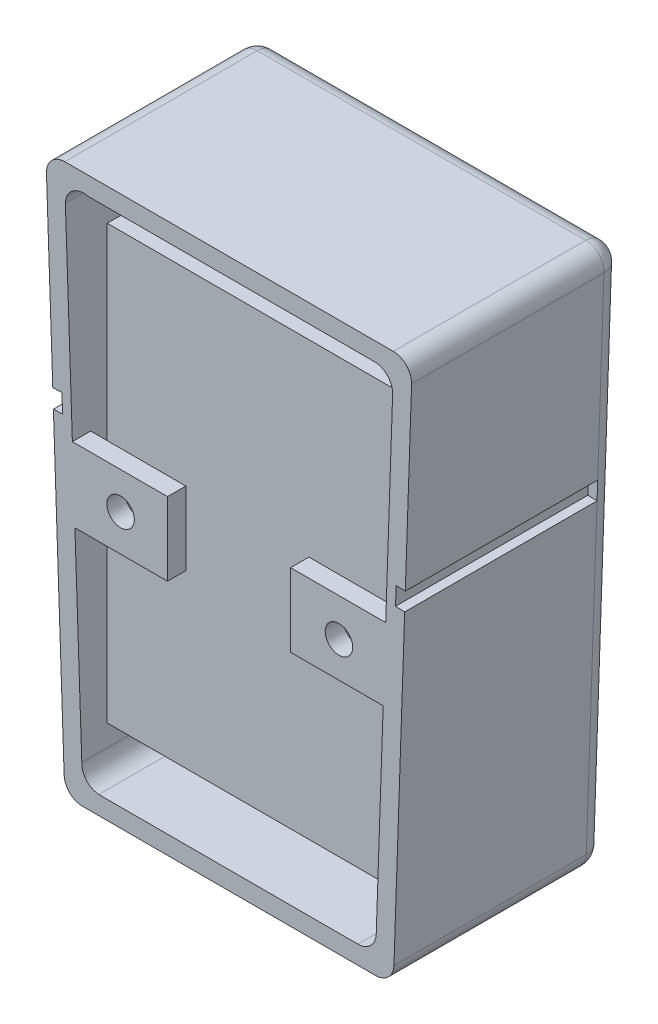
from build123d import *

# Parameters (mm, degrees)
SKETCH1_R           = 3.75
SKETCH1_R_2         = 12.75
BOSS_EXTRUDE1_DEPTH = 3.81
BOSS_EXTRUDE3_DEPTH = 25.4
BOSS_EXTRUDE4_DEPTH = 2.54
FILLET1_R           = 2.54
BOSS_EXTRUDE6_DEPTH = 2.54
SKETCH9_R           = 1.905
CUT_EXTRUDE1_DEPTH  = 2.54
CUT_EXTRUDE2_DEPTH  = 1.27
SKETCH11_W          = 26.67
SKETCH11_H          = 2.54
CUT_EXTRUDE3_DEPTH  = 1.27
SKETCH12_W          = 26.67
SKETCH12_H          = 2.54
CUT_EXTRUDE4_DEPTH  = 1.27
SKETCH13_W          = 39.9796
SKETCH13_H          = 59.9948
BOSS_EXTRUDE7_DEPTH = 10.16


with BuildPart() as part:
    # Sketch1 → Boss-Extrude1 (new body)
    with BuildSketch(Plane.XY):
        with BuildLine():
            Line((-22.77090231, 76.154735329), (22.77090231, 76.154735329))
            ThreePointArc((22.77090231, 76.154735329), (24.597640016, 75.379566583), (25.309393487, 73.527199387))
            Line((25.309393487, 73.527199387), (22.858491178, 2.452464058))
            ThreePointArc((22.858491178, 2.452464058), (22.084831254, 0.713262294), (20.32, 0))
            Line((20.32, 0), (-20.32, 0))
            ThreePointArc((-20.32, 0), (-22.084831254, 0.713262294), (-22.858491178, 2.452464058))
            Line((-22.858491178, 2.452464058), (-25.309393487, 73.527199387))
            ThreePointArc((-25.309393487, 73.527199387), (-24.597640016, 75.379566583), (-22.77090231, 76.154735329))
        make_face()
        with Locations((0, 58.539610149)):
            Circle(SKETCH1_R, mode=Mode.SUBTRACT)
        with Locations((0, 21.622308918)):
            Circle(SKETCH1_R_2, mode=Mode.SUBTRACT)
    extrude(amount=BOSS_EXTRUDE1_DEPTH)

    # Sketch4 → Boss-Extrude3 (add)
    with BuildSketch(Plane.XY.offset(3.81)):
        with BuildLine():
            Line((-22.77090231, 76.154735329), (22.77090231, 76.154735329))
            ThreePointArc((22.77090231, 76.154735329), (24.597640016, 75.379566583), (25.309393487, 73.527199387))
            Line((25.309393487, 73.527199387), (22.858491178, 2.452464058))
            ThreePointArc((22.858491178, 2.452464058), (22.084831254, 0.713262294), (20.32, 0))
            Line((20.32, 0), (-20.32, 0))
            ThreePointArc((-20.32, 0), (-22.084831254, 0.713262294), (-22.858491178, 2.452464058))
            Line((-22.858491178, 2.452464058), (-25.309393487, 73.527199387))
            ThreePointArc((-25.309393487, 73.527199387), (-24.597640016, 75.379566583), (-22.77090231, 76.154735329))
        make_face()
        with BuildLine():
            Line((-19.541270744, 73.614735329), (20.141804619, 73.614735329))
            ThreePointArc((20.141804619, 73.614735329), (21.968542325, 72.839566583), (22.680295797, 70.987199387))
            Line((22.680295797, 70.987199387), (20.404569365, 4.992462187))
            ThreePointArc((20.404569365, 4.992462187), (19.630909441, 3.253260423), (17.866078187, 2.539998129))
            Line((17.866078187, 2.539998129), (-18.061159176, 2.539998129))
            ThreePointArc((-18.061159176, 2.539998129), (-19.78310781, 3.39559701), (-20.412160003, 5.212586245))
            Line((-20.412160003, 5.212586245), (-22.687990425, 71.210339105))
            ThreePointArc((-22.687990425, 71.210339105), (-21.690891162, 73.166710129), (-19.541270744, 73.614735329))
        make_face(mode=Mode.SUBTRACT)
    extrude(amount=BOSS_EXTRUDE3_DEPTH)

    # Sketch7 → Boss-Extrude4 (add)
    with BuildSketch(Plane.XY.offset(13.335)):
        with BuildLine():
            Line((-19.537731311, 73.614735329), (20.145344052, 73.614735329))
            ThreePointArc((20.145344052, 73.614735329), (21.972081758, 72.839566583), (22.68383523, 70.987199387))
            Line((22.68383523, 70.987199387), (20.408108798, 4.992462187))
            ThreePointArc((20.408108798, 4.992462187), (19.634448874, 3.253260423), (17.86961762, 2.539998129))
            Line((17.86961762, 2.539998129), (-18.057619743, 2.539998129))
            ThreePointArc((-18.057619743, 2.539998129), (-19.730779532, 3.364707915), (-20.389382819, 5.109944754))
            Line((-20.389382819, 5.109944754), (-22.665213241, 71.107697614))
            ThreePointArc((-22.665213241, 71.107697614), (-21.714144758, 73.125513756), (-19.537731311, 73.614735329))
        make_face()
    extrude(amount=BOSS_EXTRUDE4_DEPTH)

    # Fillet1
    fillet1_edges = [part.edges().sort_by_distance(p)[0] for p in [
        (-22.084831254, 0.713262294, 0),
        (-24.083942332, 37.989831723, 0),
        (-24.597640016, 75.379566583, 0),
        (0, 76.154735329, 0),
        (24.597640016, 75.379566583, 0),
        (24.083942332, 37.989831723, 0),
        (22.084831254, 0.713262294, 0),
        (0, 0, 0),
    ]]
    fillet(fillet1_edges, radius=FILLET1_R)

    # Sketch8 → Boss-Extrude6 (add)
    with BuildSketch(Plane.XY.offset(29.21)):
        Polygon((-21.717608556, 43.069831723), (-8.531459132, 43.069831723), (-8.531459132, 32.909831723), (-21.367256671, 32.909831723), align=None)
        Polygon((8.531459132, 32.909831723), (21.367256671, 32.909831723), (21.717608556, 43.069831723), (8.531459132, 43.069831723), align=None)
    extrude(amount=-BOSS_EXTRUDE6_DEPTH)

    # Sketch9 → Cut-Extrude1 (cut)
    with BuildSketch(Plane.XY.offset(29.21)):
        with Locations((-15.036945873, 37.989831723)):
            Circle(SKETCH9_R)
        with Locations((15.237744036, 37.820383377)):
            Circle(SKETCH9_R)
    extrude(amount=-CUT_EXTRUDE1_DEPTH, mode=Mode.SUBTRACT)

    # Sketch10 → Cut-Extrude2 (cut)
    with BuildSketch(Plane(origin=(0, 0, 0), x_dir=(-1, 0, 0), z_dir=(0, 0, -1))):
        Polygon((-21.897084176, 48.274519863), (21.897084176, 48.274519863), (21.809496204, 45.734519863), (-21.809496204, 45.734519863), align=None)
    extrude(amount=-CUT_EXTRUDE2_DEPTH, mode=Mode.SUBTRACT)

    # Sketch11 → Cut-Extrude3 (cut)
    with BuildSketch(Plane(origin=(-22.746873247, -0.784390739, 0), x_dir=(0, 0, 1), z_dir=(-0.999405975, -0.034462969, 0))):
        with Locations((15.875, 47.745550873)):
            Rectangle(SKETCH11_W, SKETCH11_H)
    extrude(amount=-CUT_EXTRUDE3_DEPTH, mode=Mode.SUBTRACT)

    # Sketch12 → Cut-Extrude4 (cut)
    with BuildSketch(Plane(origin=(22.746873247, -0.784390739, 0), x_dir=(0, 0, -1), z_dir=(0.999405975, -0.034462969, 0))):
        with Locations((-15.875, 47.745550873)):
            Rectangle(SKETCH12_W, SKETCH12_H)
    extrude(amount=-CUT_EXTRUDE4_DEPTH, mode=Mode.SUBTRACT)

    # Sketch13 → Boss-Extrude7 (add)
    with BuildSketch(Plane.XY.offset(15.875)):
        with Locations((-0.0762, 38.537335329)):
            Rectangle(SKETCH13_W, SKETCH13_H)
    extrude(amount=BOSS_EXTRUDE7_DEPTH)


solid = part.part
